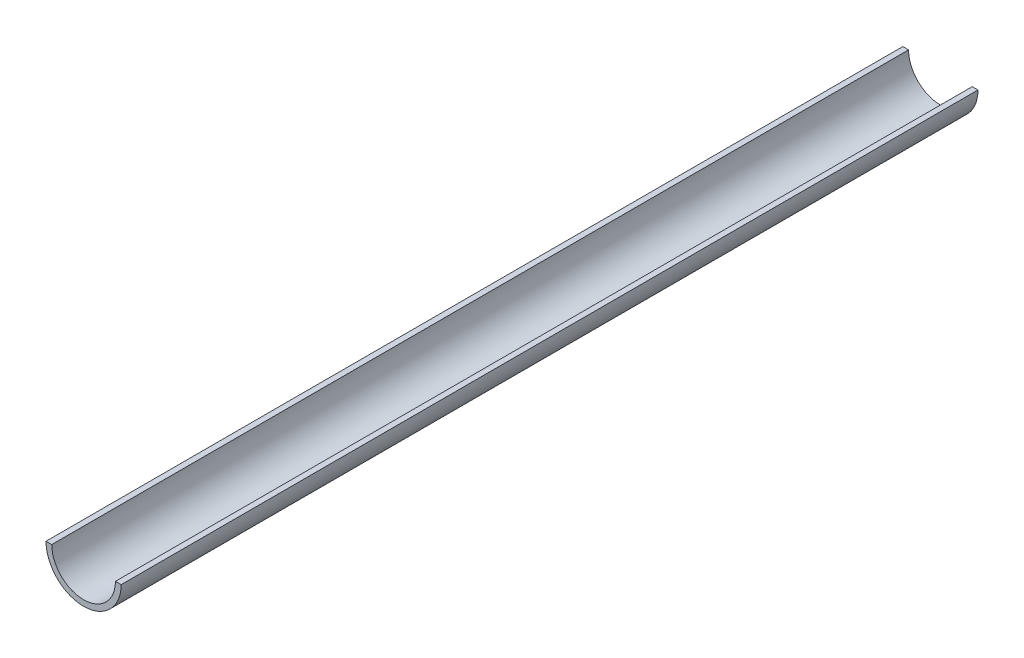
from build123d import *

# Parameters (mm, degrees)
BOSS_EXTRUDE1_DEPTH = 275.07


with BuildPart() as part:
    # Sketch1 → Boss-Extrude1 (new, symmetric)
    with BuildSketch(Plane.XY):
        with BuildLine():
            Line((-24.13, 0), (-20.445, 0))
            ThreePointArc((-20.445, 0), (0, -20.445), (20.445, 0))
            Line((20.445, 0), (24.13, 0))
            ThreePointArc((24.13, 0), (0, -24.13), (-24.13, 0))
        make_face()
    extrude(amount=BOSS_EXTRUDE1_DEPTH, both=True)


solid = part.part
